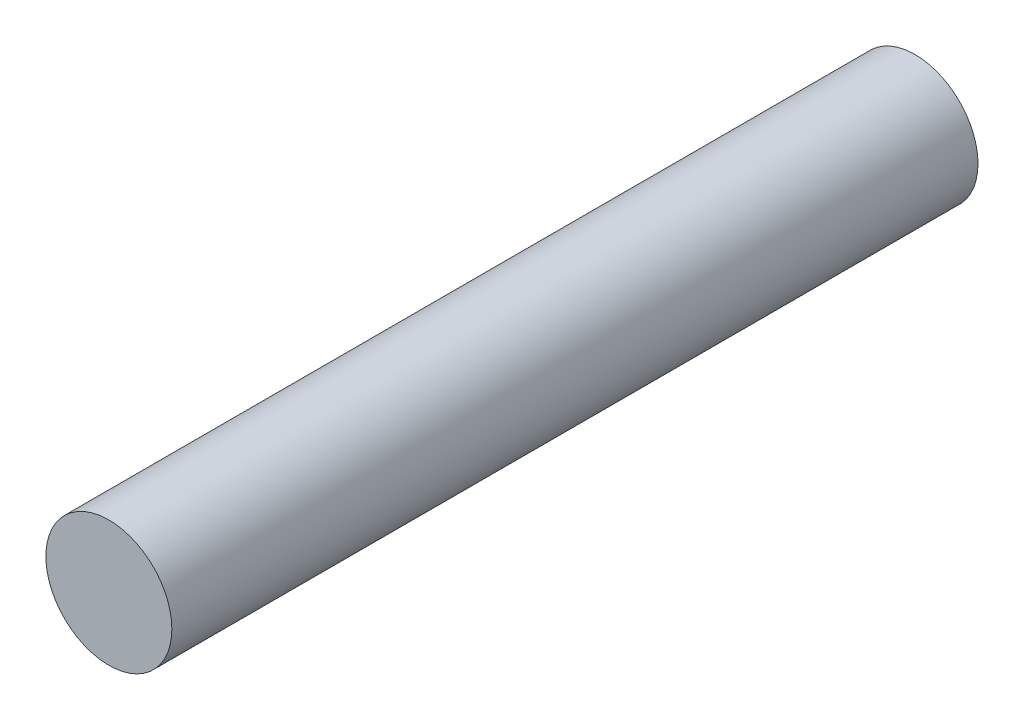
from build123d import *

# Parameters (mm, degrees)
SKETCH1_R           = 1.984375
BOSS_EXTRUDE1_DEPTH = 25.4


with BuildPart() as part:
    # Sketch1 → Boss-Extrude1 (new body)
    with BuildSketch(Plane.XY):
        Circle(SKETCH1_R)
    extrude(amount=BOSS_EXTRUDE1_DEPTH)


solid = part.part
